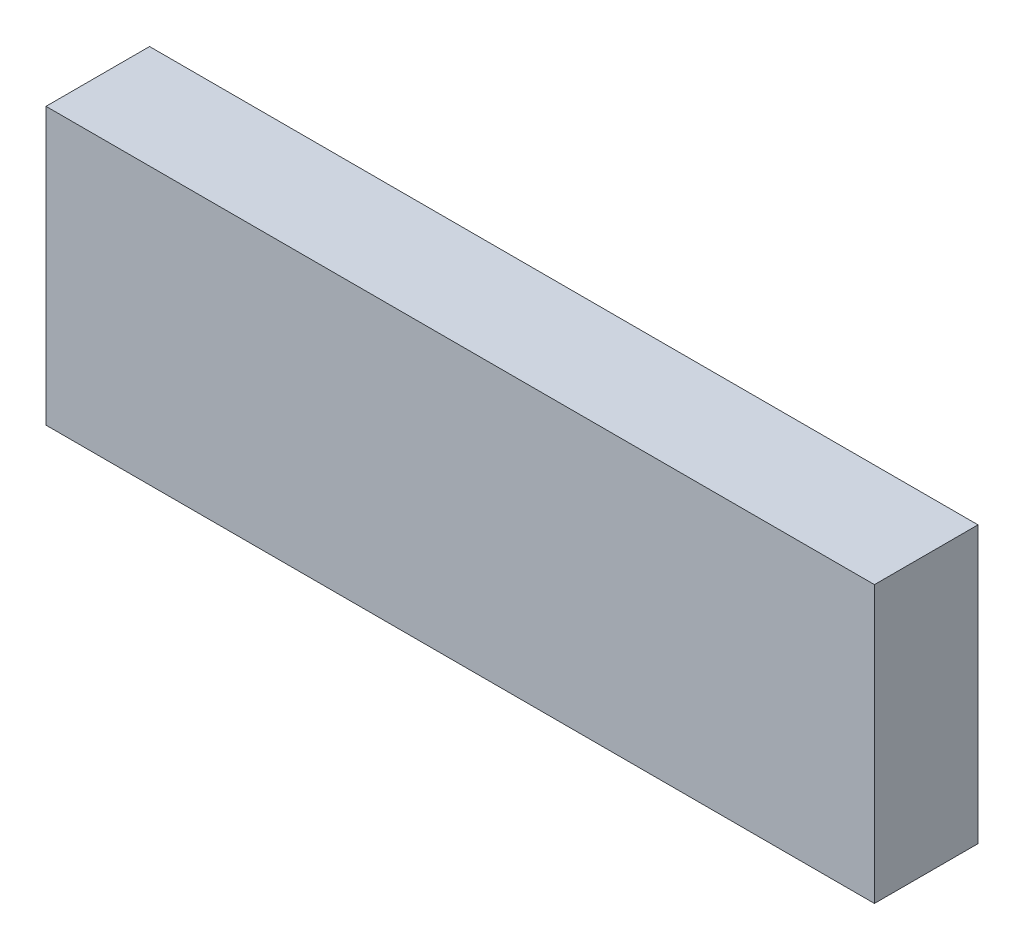
from build123d import *

# Parameters (mm, degrees)
SKETCH_1_W      = 24
SKETCH_1_H      = 8
EXTRUDE_1_DEPTH = 3


with BuildPart() as part:
    # Эскиз1 → Вытянуть1 (new body)
    with BuildSketch(Plane.XY):
        with Locations((-4.152149267, -14.5)):
            Rectangle(SKETCH_1_W, SKETCH_1_H)
    extrude(amount=EXTRUDE_1_DEPTH)


solid = part.part
